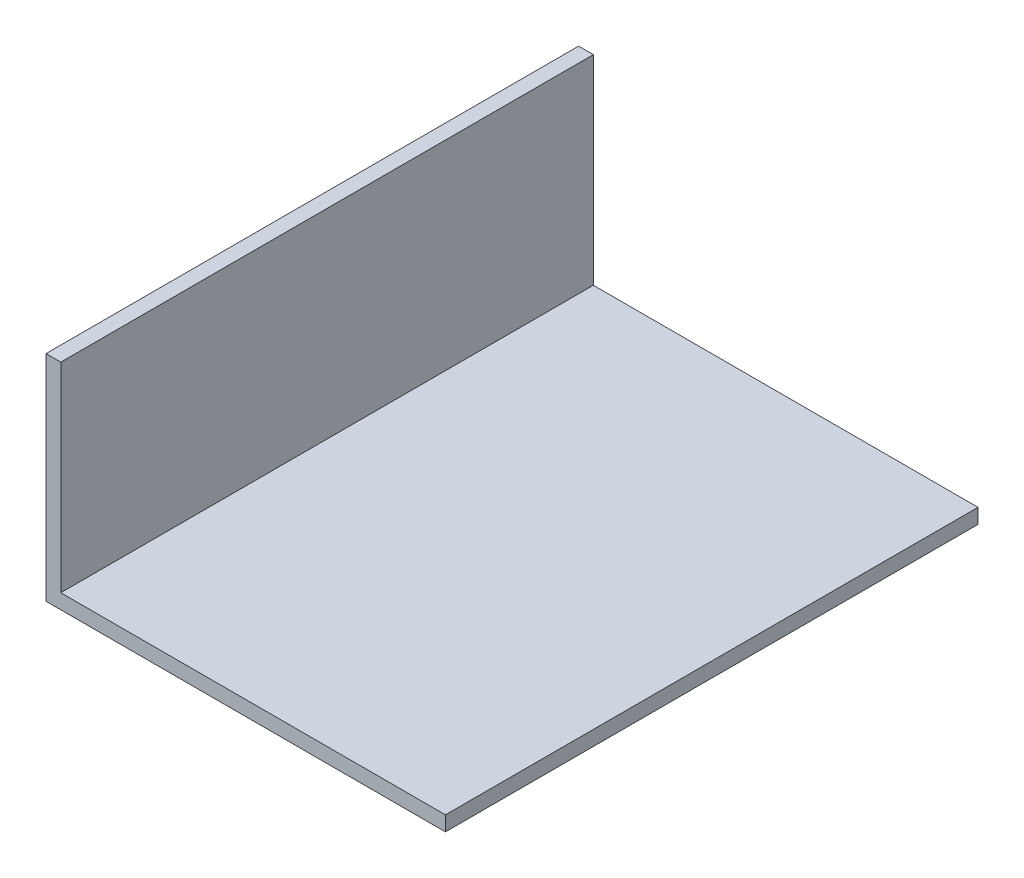
from build123d import *

# Parameters (mm, degrees)
SKETCH_1_W          = 80
SKETCH_1_H          = 40
SKETCH_1_W_2        = 76
SKETCH_1_H_2        = 36
EXTRUDE_1_DEPTH     = 72
CUT_EXTRUDE_1_DEPTH = 73


with BuildPart() as part:
    # Эскиз1 → Бобышка-Вытянуть1 (new body)
    with BuildSketch(Plane.XY):
        Rectangle(SKETCH_1_W, SKETCH_1_H)
        Rectangle(SKETCH_1_W_2, SKETCH_1_H_2, mode=Mode.SUBTRACT)
    extrude(amount=EXTRUDE_1_DEPTH)

    # Эскиз2 → Вырез-Вытянуть1 (cut, through all)
    with BuildSketch(Plane.XY.offset(72)):
        Polygon((-40, 20), (-40, 9), (-38, 9), (-38, 18), (38, 18), (38, -18), (14, -18), (14, -20), (40, -20), (40, 20), align=None)
    extrude(amount=-CUT_EXTRUDE_1_DEPTH, mode=Mode.SUBTRACT)


solid = part.part
